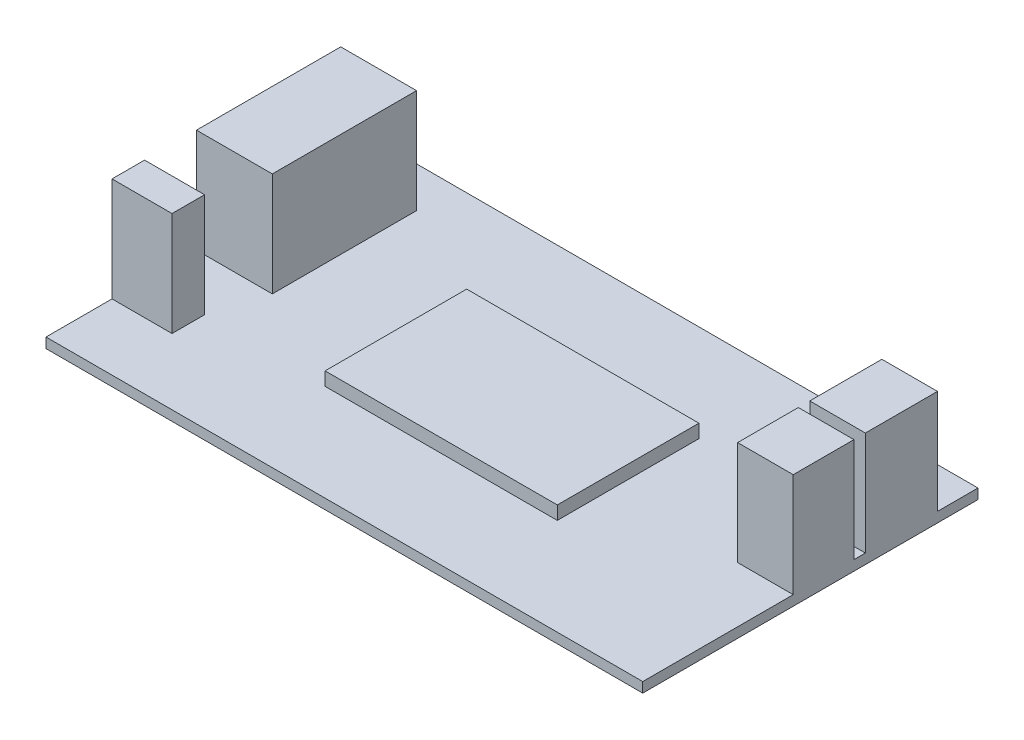
from build123d import *

# Parameters (mm, degrees)
SKETCH1_W           = 89
SKETCH1_H           = 50
BOSS_EXTRUDE1_DEPTH = 1.5
SKETCH2_W           = 11.309347118
SKETCH2_H           = 21.514889616
SKETCH2_W_2         = 8.947956794
SKETCH2_H_2         = 4.853968999
SKETCH2_W_3         = 8.292015037
SKETCH2_H_3         = 10.757444808
SKETCH2_H_4         = 9.051996241
BOSS_EXTRUDE2_DEPTH = 15.5
SKETCH3_W           = 34.633694204
SKETCH3_H           = 21.121311428
BOSS_EXTRUDE3_DEPTH = 2


with BuildPart() as part:
    # Sketch1 → Boss-Extrude1 (new body)
    with BuildSketch(Plane(origin=(0, 0, 0), x_dir=(1, 0, 0), z_dir=(0, 1, 0))):
        Rectangle(SKETCH1_W, SKETCH1_H)
    extrude(amount=BOSS_EXTRUDE1_DEPTH)

    # Sketch2 → Boss-Extrude2 (add)
    with BuildSketch(Plane(origin=(0, 1.5, 0), x_dir=(1, 0, 0), z_dir=(0, 1, 0))):
        with Locations((-38.845326441, 8.199271957)):
            Rectangle(SKETCH2_W, SKETCH2_H)
        with Locations((-40.026021603, -12.725270077)):
            Rectangle(SKETCH2_W_2, SKETCH2_H_2)
        with Locations((40.353992482, 13.577994361)):
            Rectangle(SKETCH2_W_3, SKETCH2_H_3)
        with Locations((40.353992482, 1.96782527)):
            Rectangle(SKETCH2_W_3, SKETCH2_H_4)
    extrude(amount=BOSS_EXTRUDE2_DEPTH)

    # Sketch3 → Boss-Extrude3 (add)
    with BuildSketch(Plane(origin=(0, 1.5, 0), x_dir=(1, 0, 0), z_dir=(0, 1, 0))):
        Rectangle(SKETCH3_W, SKETCH3_H)
    extrude(amount=BOSS_EXTRUDE3_DEPTH)


solid = part.part
